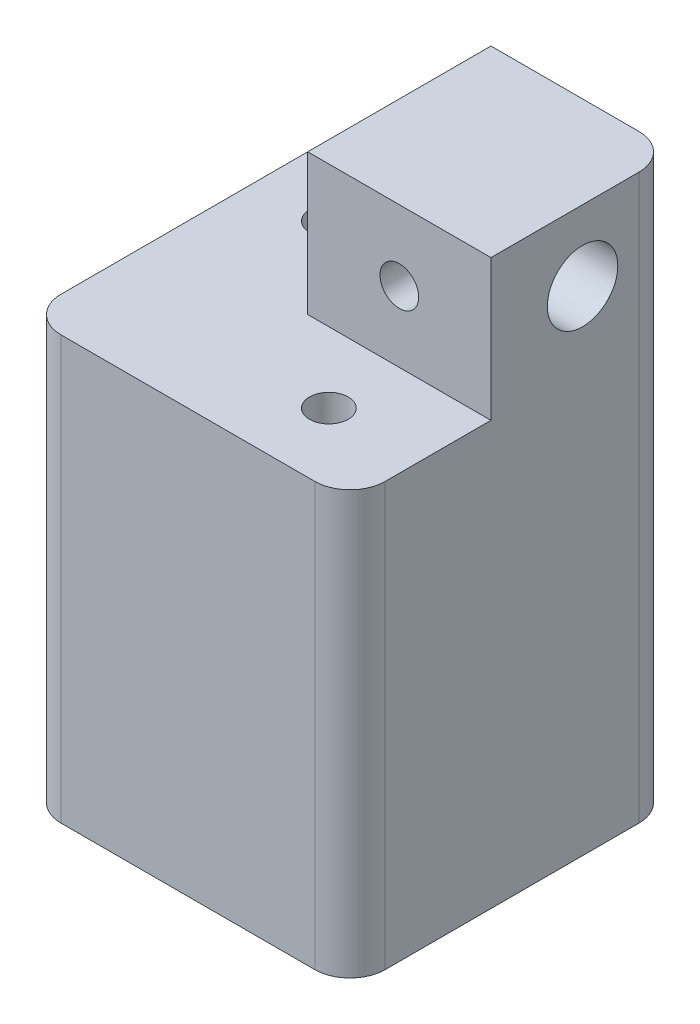
from build123d import *

# Parameters (mm, degrees)
SKETCH1_W           = 46
SKETCH1_H           = 46
BOSS_EXTRUDE1_DEPTH = 80
CUT_EXTRUDE1_DEPTH  = 20
SKETCH3_R           = 5
CUT_EXTRUDE2_DEPTH  = 21
SKETCH4_R           = 5
CUT_EXTRUDE3_DEPTH  = 21
SKETCH5_R           = 2.75
CUT_EXTRUDE4_DEPTH  = 47
SKETCH6_R           = 2.75
CUT_EXTRUDE5_DEPTH  = 47
FILLET1_R           = 5
SKETCH9_R           = 2.75
CUT_EXTRUDE8_DEPTH  = 81
SKETCH10_R          = 2.75
CUT_EXTRUDE9_DEPTH  = 61
SKETCH11_R          = 5
CUT_EXTRUDE10_DEPTH = 55


with BuildPart() as part:
    # Sketch1 → Boss-Extrude1 (new body)
    with BuildSketch(Plane(origin=(0, 0, 0), x_dir=(1, 0, 0), z_dir=(0, 1, 0))):
        with Locations((23, 23)):
            Rectangle(SKETCH1_W, SKETCH1_H)
    extrude(amount=BOSS_EXTRUDE1_DEPTH)

    # Sketch2 → Cut-Extrude1 (cut)
    with BuildSketch(Plane(origin=(0, 80, 0), x_dir=(1, 0, 0), z_dir=(0, 1, 0))):
        Polygon((0, 46), (20, 46), (20, 20), (46, 20), (46, 0), (20, 0), (0, 0), align=None)
    extrude(amount=-CUT_EXTRUDE1_DEPTH, mode=Mode.SUBTRACT)

    # Sketch3 → Cut-Extrude2 (cut)
    with BuildSketch(Plane(origin=(46, 0, 0), x_dir=(0, 0, -1), z_dir=(1, 0, 0))):
        with Locations((33, 70)):
            Circle(SKETCH3_R)
    extrude(amount=-CUT_EXTRUDE2_DEPTH, mode=Mode.SUBTRACT)

    # Sketch4 → Cut-Extrude3 (cut)
    with BuildSketch(Plane(origin=(0, 0, -46), x_dir=(-1, 0, 0), z_dir=(0, 0, -1))):
        with Locations((-33, 70)):
            Circle(SKETCH4_R)
    extrude(amount=-CUT_EXTRUDE3_DEPTH, mode=Mode.SUBTRACT)

    # Sketch5 → Cut-Extrude4 (cut, through all)
    with BuildSketch(Plane(origin=(0, 0, -46), x_dir=(-1, 0, 0), z_dir=(0, 0, -1))):
        with Locations((-33, 70)):
            Circle(SKETCH5_R)
    extrude(amount=-CUT_EXTRUDE4_DEPTH, mode=Mode.SUBTRACT)

    # Sketch6 → Cut-Extrude5 (cut, through all)
    with BuildSketch(Plane(origin=(46, 0, 0), x_dir=(0, 0, -1), z_dir=(1, 0, 0))):
        with Locations((33, 70)):
            Circle(SKETCH6_R)
    extrude(amount=-CUT_EXTRUDE5_DEPTH, mode=Mode.SUBTRACT)

    # Fillet1
    fillet1_edges = [part.edges().sort_by_distance(p)[0] for p in [
        (0, 30, -46),
        (46, 30, 0),
        (0, 30, 0),
        (46, 40, -46),
    ]]
    fillet(fillet1_edges, radius=FILLET1_R)

    # Sketch9 → Cut-Extrude8 (cut, through all)
    with BuildSketch(Plane.XZ):
        with Locations((10, -33)):
            Circle(SKETCH9_R)
    extrude(amount=-CUT_EXTRUDE8_DEPTH, mode=Mode.SUBTRACT)

    # Sketch10 → Cut-Extrude9 (cut, through all)
    with BuildSketch(Plane(origin=(0, 60, 0), x_dir=(1, 0, 0), z_dir=(0, 1, 0))):
        with Locations((33, 10)):
            Circle(SKETCH10_R)
    extrude(amount=-CUT_EXTRUDE9_DEPTH, mode=Mode.SUBTRACT)

    # Sketch11 → Cut-Extrude10 (cut)
    with BuildSketch(Plane.XZ):
        with Locations((33, -10)):
            Circle(SKETCH11_R)
        with Locations((10, -33)):
            Circle(SKETCH11_R)
    extrude(amount=-CUT_EXTRUDE10_DEPTH, mode=Mode.SUBTRACT)


solid = part.part
